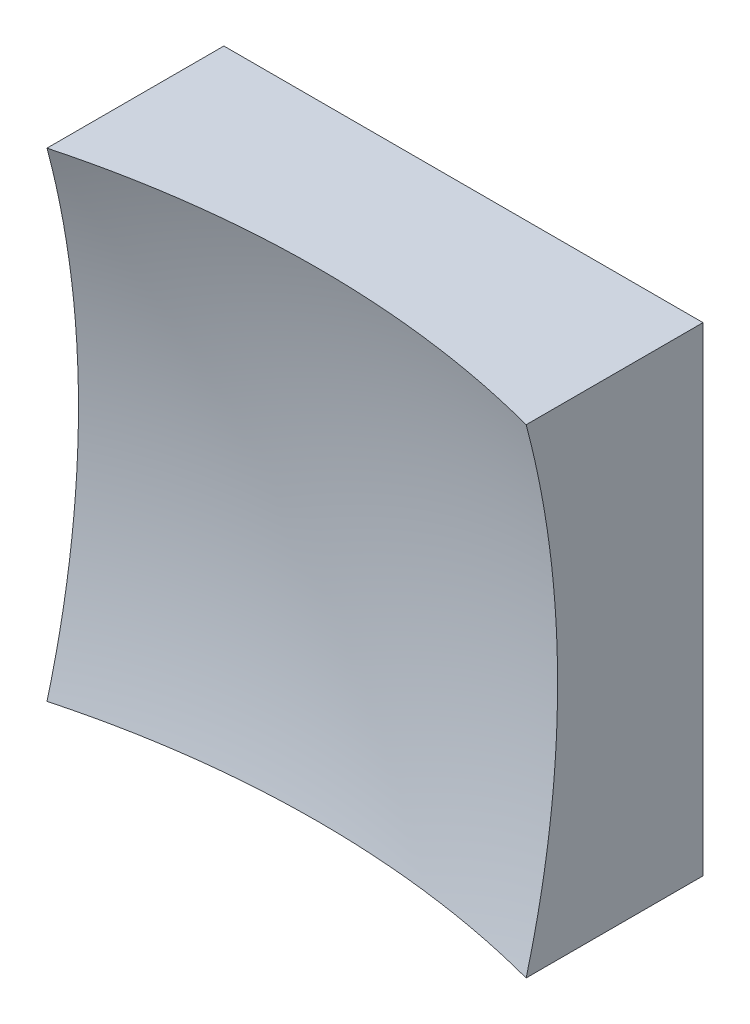
from build123d import *

# Parameters (mm, degrees)
SKETCH_1_W      = 25
SKETCH_1_H      = 25
EXTRUDE_1_DEPTH = 20


with BuildPart() as part:
    # 草图1 → 凸台-拉伸1 (new body)
    with BuildSketch(Plane.XY):
        Rectangle(SKETCH_1_W, SKETCH_1_H)
    extrude(amount=EXTRUDE_1_DEPTH)

    # 草图2 → 切除-旋转2 (revolve, cut)
    with BuildSketch(Plane(origin=(0, 0, 0), x_dir=(1, 0, 0), z_dir=(0, 1, 0))):
        with BuildLine():
            Line((48.742273091, -44.855906768), (0, -44.855906768))
            Line((0, -44.855906768), (0, -6))
            ThreePointArc((0, -6), (31.167253155, -16.902655707), (48.742273091, -44.855906768))
        make_face()
    revolve(axis=Axis((0, 0, 44.855906768), (0, 0, -1)), mode=Mode.SUBTRACT)


solid = part.part
